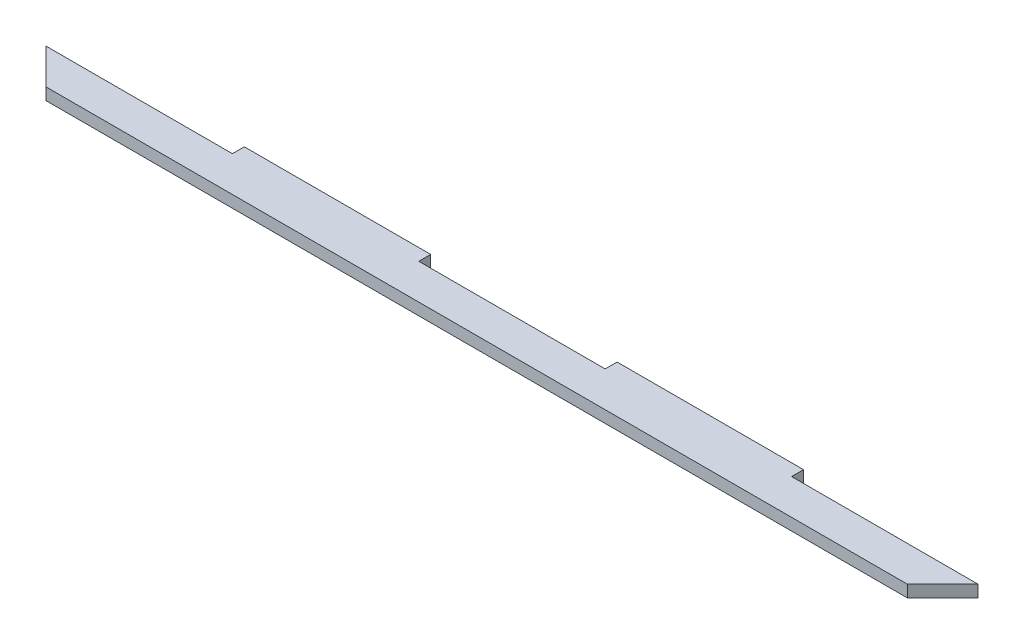
from build123d import *

# Parameters (mm, degrees)
BOSS_EXTRUDE1_DEPTH = 2.7


with BuildPart() as part:
    # Sketch1 → Boss-Extrude1 (new body)
    with BuildSketch(Plane(origin=(0, 0, 0), x_dir=(1, 0, 0), z_dir=(0, 1, 0))):
        Polygon((-37.031304348, 2.735714843), (5.168695652, 2.735714843), (5.168695652, 5.435714843), (47.368695652, 5.435714843), (47.368695652, 2.735714843), (89.568695652, 2.735714843), (89.568695652, 5.435714843), (131.768695652, 5.435714843), (131.768695652, 2.735714843), (173.968695652, 2.735714843), (165.968695652, -5.264285157), (-29.031304348, -5.264285157), align=None)
    extrude(amount=BOSS_EXTRUDE1_DEPTH)


solid = part.part
